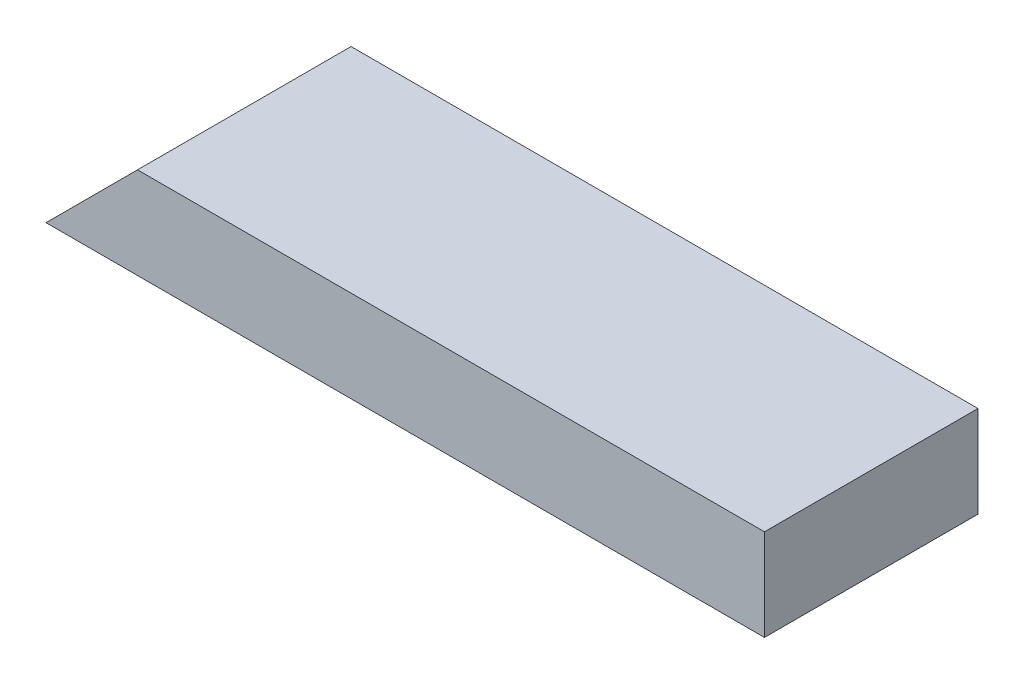
from build123d import *

# Parameters (mm, degrees)
SKETCH1_W           = 299.0977
SKETCH1_H           = 88.9
BOSS_EXTRUDE1_DEPTH = 38.1
CUT_EXTRUDE1_DEPTH  = 89.9


with BuildPart() as part:
    # Sketch1 → Boss-Extrude1 (new body)
    with BuildSketch(Plane(origin=(0, 0, 0), x_dir=(1, 0, 0), z_dir=(0, 1, 0))):
        with Locations((149.54885, 44.45)):
            Rectangle(SKETCH1_W, SKETCH1_H)
    extrude(amount=BOSS_EXTRUDE1_DEPTH)

    # Sketch2 → Cut-Extrude1 (cut, through all)
    with BuildSketch(Plane.XY):
        Polygon((0, 0), (38.1, 38.1), (0, 38.1), align=None)
    extrude(amount=-CUT_EXTRUDE1_DEPTH, mode=Mode.SUBTRACT)


solid = part.part
